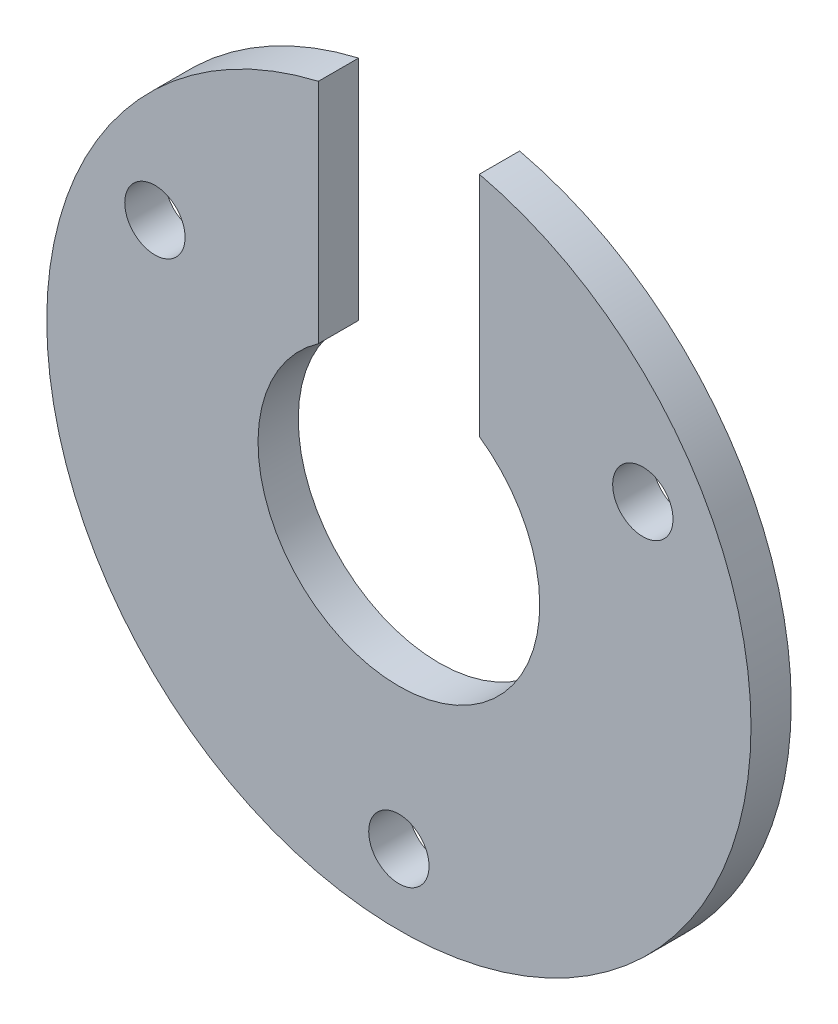
from build123d import *

# Parameters (mm, degrees)
SKETCH1_R                = 17.5
SKETCH1_R_2              = 7
EXTRUDE1_DEPTH           = 2
SKETCH2_W                = 8
SKETCH2_H                = 16.5675126
CUT_EXTRUDE1_DEPTH       = 2
F_3_0_3_DIAMETER_HOLE1_D = 3


with BuildPart() as part:
    # Sketch1 → Extrude1 (new body)
    with BuildSketch(Plane.XY):
        Circle(SKETCH1_R)
        Circle(SKETCH1_R_2, mode=Mode.SUBTRACT)
    extrude(amount=EXTRUDE1_DEPTH)

    # Sketch2 → Cut-Extrude1 (cut)
    with BuildSketch(Plane.XY.offset(2)):
        with Locations((0, 11.499771479)):
            Rectangle(SKETCH2_W, SKETCH2_H)
    extrude(amount=-CUT_EXTRUDE1_DEPTH, mode=Mode.SUBTRACT)

    # Ø3.0 (3) Diameter Hole1 (through all)
    with Locations(Plane(origin=(0, -14, 0), x_dir=(-1, 0, 0), z_dir=(0, 0, -1))):
        with Locations((0, 0), (12.124355653, 21), (-12.124355653, 21)):
            Hole(F_3_0_3_DIAMETER_HOLE1_D / 2)


solid = part.part
